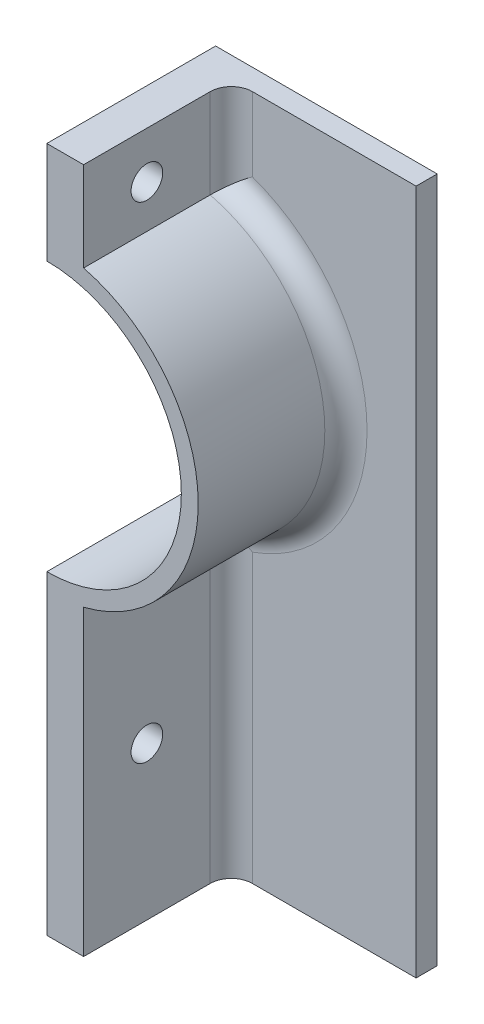
from build123d import *

# Parameters (mm, degrees)
BOSS_EXTRUDE3_DEPTH     = 20.32
BOSS_EXTRUDE4_DEPTH     = 2.54
FILLET2_R               = 2.54
CUT_EXTRUDE2_DEPTH      = 100.035573995
CUT_EXTRUDE2_DEPTH_BACK = 100.035573995
SKETCH3_R               = 1.905


with BuildPart() as part:
    # Sketch2 → Boss-Extrude3 (new body)
    with BuildSketch(Plane.XY):
        with BuildLine():
            Line((24.13, 37.9095), (24.13, 0))
            Line((24.13, 0), (28.557757617, 0))
            Line((28.557757617, 0), (28.557757617, 36.423556552))
            ThreePointArc((28.557757617, 36.423556552), (42.3545, 54.102), (28.557757617, 71.780443448))
            Line((28.557757617, 71.780443448), (28.557757617, 82.55))
            Line((28.557757617, 82.55), (24.13, 82.55))
            Line((24.13, 82.55), (24.13, 70.2945))
            ThreePointArc((24.13, 70.2945), (35.579826554, 65.551826554), (40.3225, 54.102))
            ThreePointArc((40.3225, 54.102), (35.579826554, 42.652173446), (24.13, 37.9095))
        make_face()
    extrude(amount=BOSS_EXTRUDE3_DEPTH)

    # Sketch2_5 → Boss-Extrude4 (add)
    with BuildSketch(Plane.XY):
        with BuildLine():
            Line((28.557757617, 36.423556552), (28.557757617, 0))
            Line((28.557757617, 0), (50.8, 0))
            Line((50.8, 0), (50.8, 82.55))
            Line((50.8, 82.55), (28.557757617, 82.55))
            Line((28.557757617, 82.55), (28.557757617, 71.780443448))
            ThreePointArc((28.557757617, 71.780443448), (42.3545, 54.102), (28.557757617, 36.423556552))
        make_face()
    extrude(amount=BOSS_EXTRUDE4_DEPTH)

    # Fillet2
    fillet2_edges = [part.edges().sort_by_distance(p)[0] for p in [
        (28.557757617, 18.211778276, 2.54),
        (28.557757617, 77.165221724, 2.54),
        (42.3545, 54.102, 2.54),
    ]]
    fillet(fillet2_edges, radius=FILLET2_R)

    # Sketch3 → Cut-Extrude2 (cut, two sides: drawn at the far end of the back side and taken through both)
    with BuildSketch(Plane(origin=(0, 0, 0), x_dir=(0, 0, -1), z_dir=(1, 0, 0)).offset(-CUT_EXTRUDE2_DEPTH_BACK)):
        with Locations((-12.7, 18.430889618)):
            Circle(SKETCH3_R)
        with Locations((-12.7, 76.946110382)):
            Circle(SKETCH3_R)
    extrude(amount=CUT_EXTRUDE2_DEPTH + CUT_EXTRUDE2_DEPTH_BACK, mode=Mode.SUBTRACT)


solid = part.part
